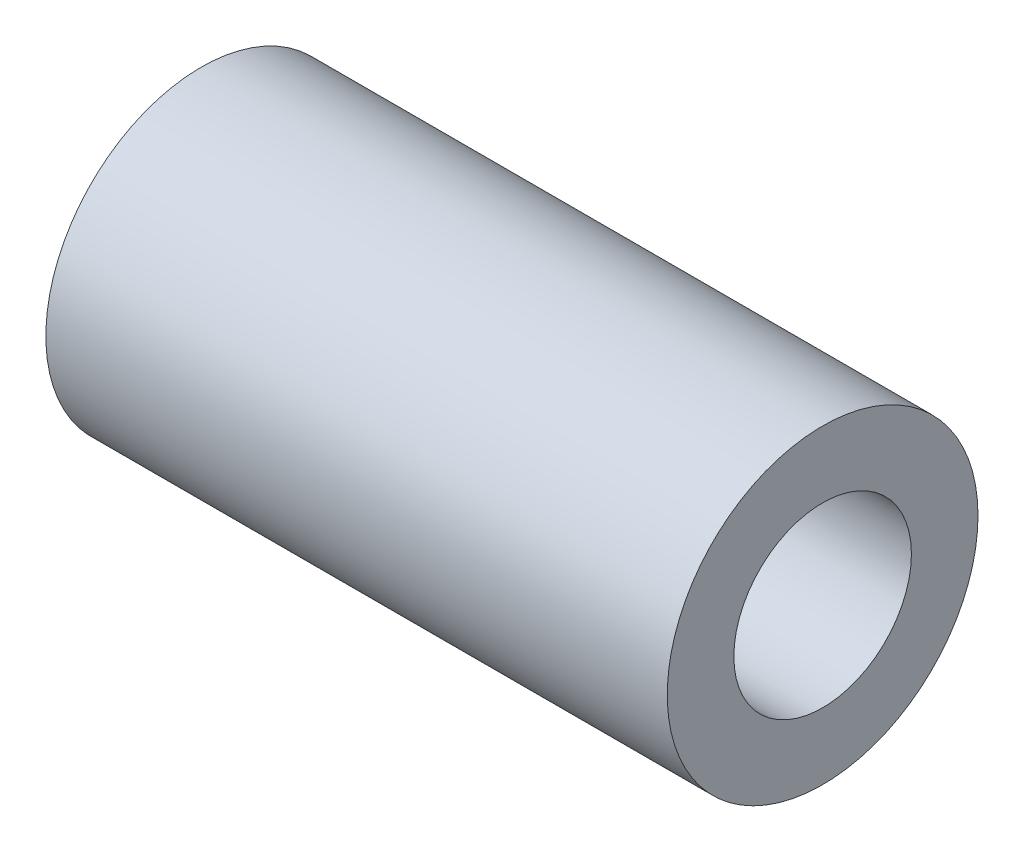
from build123d import *

# Parameters (mm, degrees)
CROQUIS1_R              = 7
CROQUIS1_R_2            = 4
SALIENTE_EXTRUIR1_DEPTH = 28


with BuildPart() as part:
    # Croquis1 → Saliente-Extruir1 (new body)
    with BuildSketch(Plane(origin=(0, 0, 0), x_dir=(0, 0, -1), z_dir=(1, 0, 0))):
        Circle(CROQUIS1_R)
        Circle(CROQUIS1_R_2, mode=Mode.SUBTRACT)
    extrude(amount=-SALIENTE_EXTRUIR1_DEPTH)


solid = part.part
